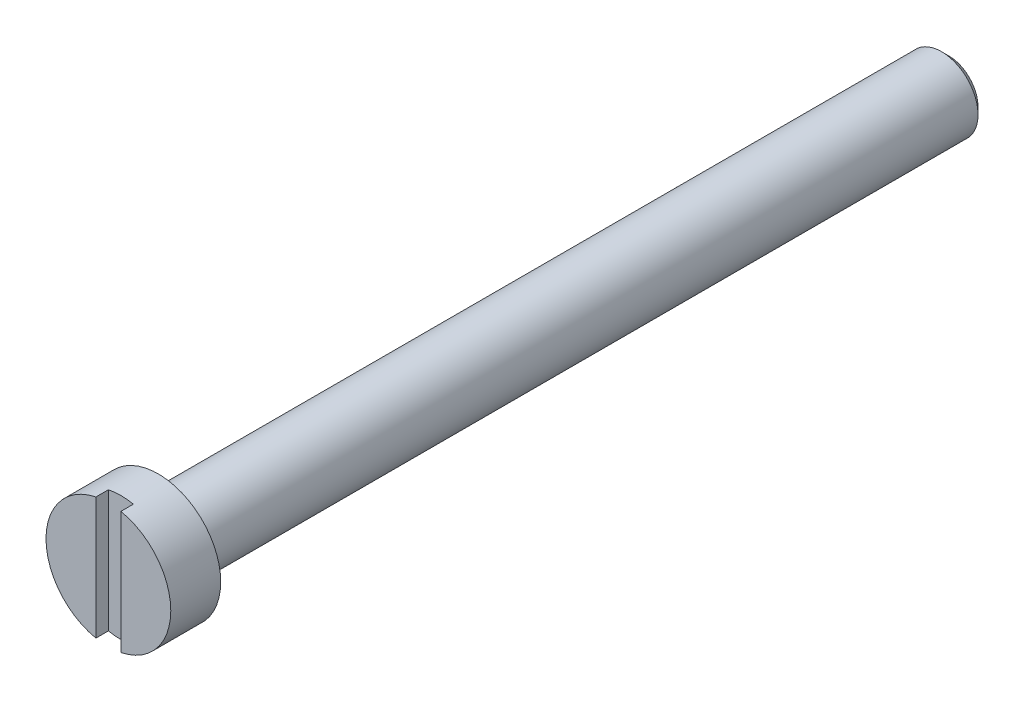
from build123d import *

# Parameters (mm, degrees)
SKETCH_1_R               = 3
EXTRUDE_1_DEPTH          = 2.4
SKETCH_2_R               = 1.75
EXTRUDE_2_DEPTH          = 38
CHAMFER_1_SIZE           = 0.3355
CUT_EXTRUDE_1_DEPTH      = 38
CUT_EXTRUDE_1_DEPTH_BACK = 38
SKETCH_3_W               = 1.2
SKETCH_3_H               = 1.2


with BuildPart() as part:
    # Эскиз1 → Бобышка-Вытянуть1 (new body)
    with BuildSketch(Plane.XY):
        Circle(SKETCH_1_R)
    extrude(amount=EXTRUDE_1_DEPTH)

    # Эскиз2 → Бобышка-Вытянуть2 (add)
    with BuildSketch(Plane(origin=(0, 0, 0), x_dir=(-1, 0, 0), z_dir=(0, 0, -1))):
        Circle(SKETCH_2_R)
    extrude(amount=EXTRUDE_2_DEPTH)

    # Фаска1
    chamfer_1_edges = [part.edges().sort_by_distance(p)[0] for p in [
        (1.75, 0, -38),
    ]]
    chamfer(chamfer_1_edges, length=CHAMFER_1_SIZE)

    # Эскиз3 → Вырез-Вытянуть1 (cut, two sides: drawn at the far end of the back side and taken through both)
    with BuildSketch(Plane(origin=(0, 0, 0), x_dir=(1, 0, 0), z_dir=(0, 1, 0)).offset(-CUT_EXTRUDE_1_DEPTH_BACK)):
        with Locations((0, -2.4)):
            Rectangle(SKETCH_3_W, SKETCH_3_H)
    extrude(amount=CUT_EXTRUDE_1_DEPTH + CUT_EXTRUDE_1_DEPTH_BACK, mode=Mode.SUBTRACT)


solid = part.part
